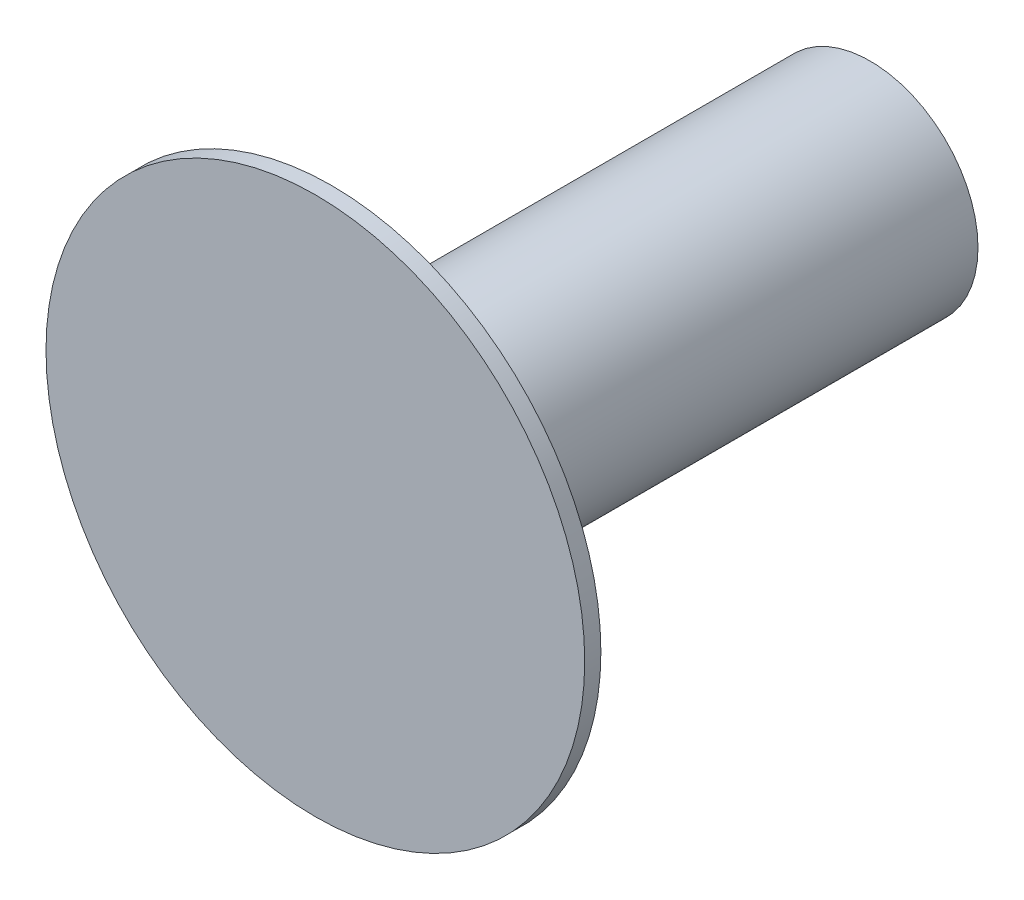
from build123d import *

# Parameters (mm, degrees)
SKETCH2_R           = 10
BOSS_EXTRUDE1_DEPTH = 0.6
SKETCH3_R           = 4
BOSS_EXTRUDE2_DEPTH = 20


with BuildPart() as part:
    # Sketch2 → Boss-Extrude1 (new body)
    with BuildSketch(Plane.XY):
        Circle(SKETCH2_R)
    extrude(amount=BOSS_EXTRUDE1_DEPTH)

    # Sketch3 → Boss-Extrude2 (add)
    with BuildSketch(Plane(origin=(0, 0, 0), x_dir=(-1, 0, 0), z_dir=(0, 0, -1))):
        Circle(SKETCH3_R)
    extrude(amount=BOSS_EXTRUDE2_DEPTH)


solid = part.part
